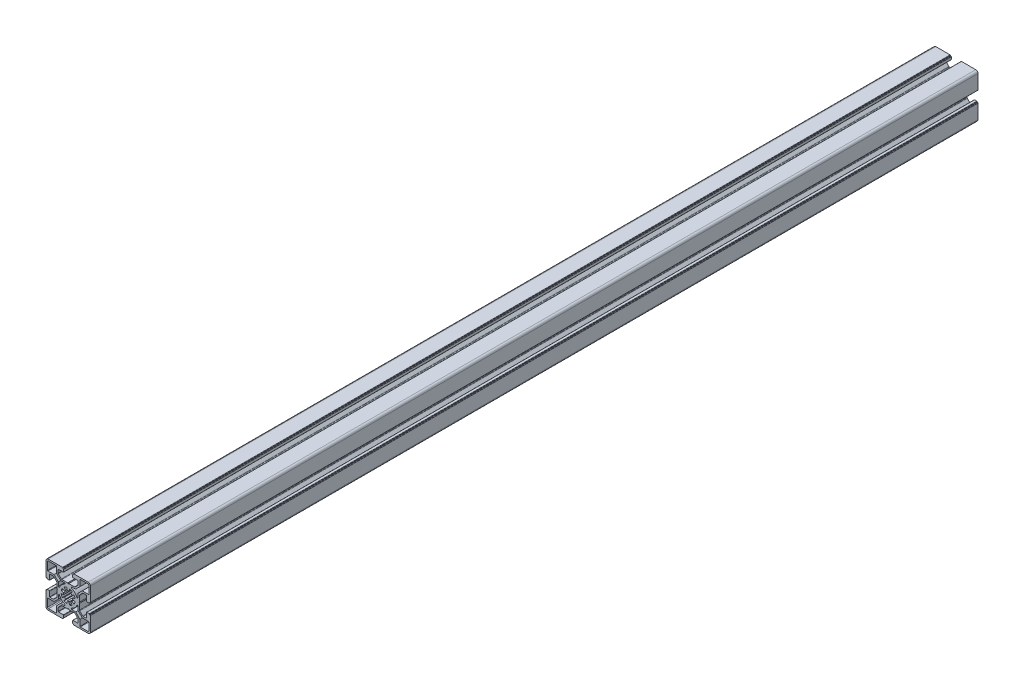
from build123d import *

# Parameters (mm, degrees)
EXTRUDE_2_DEPTH = 1000


with BuildPart() as part:
    # Эскиз2 → Бобышка-Вытянуть2 (new body)
    with BuildSketch(Plane.XY):
        with BuildLine():
            Line((-25, 11.3), (-25, 22.5))
            ThreePointArc((-25, 22.5), (-24.267766953, 24.267766953), (-22.5, 25))
            Line((-22.5, 25), (-11.3, 25))
            Line((-11.3, 25), (-6.4, 25))
            ThreePointArc((-6.4, 25), (-6.187867966, 24.912132034), (-6.1, 24.7))
            Line((-6.1, 24.7), (-6.1, 24))
            Line((-6.1, 24), (-5.4, 24))
            ThreePointArc((-5.4, 24), (-5.187867966, 23.912132034), (-5.1, 23.7))
            Line((-5.1, 23.7), (-5.1, 21.1))
            ThreePointArc((-5.1, 21.1), (-5.187867966, 20.887867966), (-5.4, 20.8))
            Line((-5.4, 20.8), (-11, 20.8))
            ThreePointArc((-11, 20.8), (-11.212132034, 20.712132034), (-11.3, 20.5))
            Line((-11.3, 20.5), (-11.3, 16.914213562))
            ThreePointArc((-11.3, 16.914213562), (-11.223879533, 16.53153013), (-11.007106781, 16.207106781))
            Line((-11.007106781, 16.207106781), (-7.792893219, 12.992893219))
            ThreePointArc((-7.792893219, 12.992893219), (-7.46846987, 12.776120467), (-7.085786438, 12.7))
            Line((-7.085786438, 12.7), (-0.6, 12.7))
            Line((-0.6, 12.7), (0, 12.1))
            Line((0, 12.1), (0.6, 12.7))
            Line((0.6, 12.7), (7.085786438, 12.7))
            ThreePointArc((7.085786438, 12.7), (7.46846987, 12.776120467), (7.792893219, 12.992893219))
            Line((7.792893219, 12.992893219), (11.007106781, 16.207106781))
            ThreePointArc((11.007106781, 16.207106781), (11.223879533, 16.53153013), (11.3, 16.914213562))
            Line((11.3, 16.914213562), (11.3, 20.5))
            ThreePointArc((11.3, 20.5), (11.212132034, 20.712132034), (11, 20.8))
            Line((11, 20.8), (5.4, 20.8))
            ThreePointArc((5.4, 20.8), (5.187867966, 20.887867966), (5.1, 21.1))
            Line((5.1, 21.1), (5.1, 23.7))
            ThreePointArc((5.1, 23.7), (5.187867966, 23.912132034), (5.4, 24))
            Line((5.4, 24), (6.1, 24))
            Line((6.1, 24), (6.1, 24.7))
            ThreePointArc((6.1, 24.7), (6.187867966, 24.912132034), (6.4, 25))
            Line((6.4, 25), (11.3, 25))
            Line((11.3, 25), (22.5, 25))
            ThreePointArc((22.5, 25), (24.267766953, 24.267766953), (25, 22.5))
            Line((25, 22.5), (25, 11.3))
            Line((25, 11.3), (25, 6.4))
            ThreePointArc((25, 6.4), (24.912132034, 6.187867966), (24.7, 6.1))
            Line((24.7, 6.1), (24, 6.1))
            Line((24, 6.1), (24, 5.4))
            ThreePointArc((24, 5.4), (23.912132034, 5.187867966), (23.7, 5.1))
            Line((23.7, 5.1), (21.1, 5.1))
            ThreePointArc((21.1, 5.1), (20.887867966, 5.187867966), (20.8, 5.4))
            Line((20.8, 5.4), (20.8, 11))
            ThreePointArc((20.8, 11), (20.712132034, 11.212132034), (20.5, 11.3))
            Line((20.5, 11.3), (16.914213562, 11.3))
            ThreePointArc((16.914213562, 11.3), (16.53153013, 11.223879533), (16.207106781, 11.007106781))
            Line((16.207106781, 11.007106781), (12.992893219, 7.792893219))
            ThreePointArc((12.992893219, 7.792893219), (12.776120467, 7.46846987), (12.7, 7.085786438))
            Line((12.7, 7.085786438), (12.7, 0.6))
            Line((12.7, 0.6), (12.1, 0))
            Line((12.1, 0), (12.7, -0.6))
            Line((12.7, -0.6), (12.7, -7.085786438))
            ThreePointArc((12.7, -7.085786438), (12.776120467, -7.46846987), (12.992893219, -7.792893219))
            Line((12.992893219, -7.792893219), (16.207106781, -11.007106781))
            ThreePointArc((16.207106781, -11.007106781), (16.53153013, -11.223879533), (16.914213562, -11.3))
            Line((16.914213562, -11.3), (20.5, -11.3))
            ThreePointArc((20.5, -11.3), (20.712132034, -11.212132034), (20.8, -11))
            Line((20.8, -11), (20.8, -5.4))
            ThreePointArc((20.8, -5.4), (20.887867966, -5.187867966), (21.1, -5.1))
            Line((21.1, -5.1), (23.7, -5.1))
            ThreePointArc((23.7, -5.1), (23.912132034, -5.187867966), (24, -5.4))
            Line((24, -5.4), (24, -6.1))
            Line((24, -6.1), (24.7, -6.1))
            ThreePointArc((24.7, -6.1), (24.912132034, -6.187867966), (25, -6.4))
            Line((25, -6.4), (25, -11.3))
            Line((25, -11.3), (25, -22.5))
            ThreePointArc((25, -22.5), (24.267766953, -24.267766953), (22.5, -25))
            Line((22.5, -25), (11.3, -25))
            Line((11.3, -25), (6.4, -25))
            ThreePointArc((6.4, -25), (6.187867966, -24.912132034), (6.1, -24.7))
            Line((6.1, -24.7), (6.1, -24))
            Line((6.1, -24), (5.4, -24))
            ThreePointArc((5.4, -24), (5.187867966, -23.912132034), (5.1, -23.7))
            Line((5.1, -23.7), (5.1, -21.1))
            ThreePointArc((5.1, -21.1), (5.187867966, -20.887867966), (5.4, -20.8))
            Line((5.4, -20.8), (11, -20.8))
            ThreePointArc((11, -20.8), (11.212132034, -20.712132034), (11.3, -20.5))
            Line((11.3, -20.5), (11.3, -16.914213562))
            ThreePointArc((11.3, -16.914213562), (11.223879533, -16.53153013), (11.007106781, -16.207106781))
            Line((11.007106781, -16.207106781), (7.792893219, -12.992893219))
            ThreePointArc((7.792893219, -12.992893219), (7.46846987, -12.776120467), (7.085786438, -12.7))
            Line((7.085786438, -12.7), (0.6, -12.7))
            Line((0.6, -12.7), (0, -12.1))
            Line((0, -12.1), (-0.6, -12.7))
            Line((-0.6, -12.7), (-7.085786438, -12.7))
            ThreePointArc((-7.085786438, -12.7), (-7.46846987, -12.776120467), (-7.792893219, -12.992893219))
            Line((-7.792893219, -12.992893219), (-11.007106781, -16.207106781))
            ThreePointArc((-11.007106781, -16.207106781), (-11.223879533, -16.53153013), (-11.3, -16.914213562))
            Line((-11.3, -16.914213562), (-11.3, -20.5))
            ThreePointArc((-11.3, -20.5), (-11.212132034, -20.712132034), (-11, -20.8))
            Line((-11, -20.8), (-5.4, -20.8))
            ThreePointArc((-5.4, -20.8), (-5.187867966, -20.887867966), (-5.1, -21.1))
            Line((-5.1, -21.1), (-5.1, -23.7))
            ThreePointArc((-5.1, -23.7), (-5.187867966, -23.912132034), (-5.4, -24))
            Line((-5.4, -24), (-6.1, -24))
            Line((-6.1, -24), (-6.1, -24.7))
            ThreePointArc((-6.1, -24.7), (-6.187867966, -24.912132034), (-6.4, -25))
            Line((-6.4, -25), (-11.3, -25))
            Line((-11.3, -25), (-22.5, -25))
            ThreePointArc((-22.5, -25), (-24.267766953, -24.267766953), (-25, -22.5))
            Line((-25, -22.5), (-25, -11.3))
            Line((-25, -11.3), (-25, -6.4))
            ThreePointArc((-25, -6.4), (-24.912132034, -6.187867966), (-24.7, -6.1))
            Line((-24.7, -6.1), (-24, -6.1))
            Line((-24, -6.1), (-24, -5.4))
            ThreePointArc((-24, -5.4), (-23.912132034, -5.187867966), (-23.7, -5.1))
            Line((-23.7, -5.1), (-21.1, -5.1))
            ThreePointArc((-21.1, -5.1), (-20.887867966, -5.187867966), (-20.8, -5.4))
            Line((-20.8, -5.4), (-20.8, -11))
            ThreePointArc((-20.8, -11), (-20.712132034, -11.212132034), (-20.5, -11.3))
            Line((-20.5, -11.3), (-16.914213562, -11.3))
            ThreePointArc((-16.914213562, -11.3), (-16.53153013, -11.223879533), (-16.207106781, -11.007106781))
            Line((-16.207106781, -11.007106781), (-12.992893219, -7.792893219))
            ThreePointArc((-12.992893219, -7.792893219), (-12.776120467, -7.46846987), (-12.7, -7.085786438))
            Line((-12.7, -7.085786438), (-12.7, -0.6))
            Line((-12.7, -0.6), (-12.1, 0))
            Line((-12.1, 0), (-12.7, 0.6))
            Line((-12.7, 0.6), (-12.7, 7.085786438))
            ThreePointArc((-12.7, 7.085786438), (-12.776120467, 7.46846987), (-12.992893219, 7.792893219))
            Line((-12.992893219, 7.792893219), (-16.207106781, 11.007106781))
            ThreePointArc((-16.207106781, 11.007106781), (-16.53153013, 11.223879533), (-16.914213562, 11.3))
            Line((-16.914213562, 11.3), (-20.5, 11.3))
            ThreePointArc((-20.5, 11.3), (-20.712132034, 11.212132034), (-20.8, 11))
            Line((-20.8, 11), (-20.8, 5.4))
            ThreePointArc((-20.8, 5.4), (-20.887867966, 5.187867966), (-21.1, 5.1))
            Line((-21.1, 5.1), (-23.7, 5.1))
            ThreePointArc((-23.7, 5.1), (-23.912132034, 5.187867966), (-24, 5.4))
            Line((-24, 5.4), (-24, 6.1))
            Line((-24, 6.1), (-24.7, 6.1))
            ThreePointArc((-24.7, 6.1), (-24.912132034, 6.187867966), (-25, 6.4))
            Line((-25, 6.4), (-25, 11.3))
        make_face()
        with BuildLine():
            Line((-11.1, 8.412994231), (-11.1, 4.156921938))
            ThreePointArc((-11.1, 4.156921938), (-10.532287566, 3.469535584), (-9.75, 3.897114317))
            ThreePointArc((-9.75, 3.897114317), (-7.424621202, 7.424621202), (-3.897114317, 9.75))
            ThreePointArc((-3.897114317, 9.75), (-3.469535584, 10.532287566), (-4.156921938, 11.1))
            Line((-4.156921938, 11.1), (-8.412994231, 11.1))
            Line((-8.412994231, 11.1), (-13.2, 15.887005769))
            Line((-13.2, 15.887005769), (-13.2, 22.7))
            ThreePointArc((-13.2, 22.7), (-13.346446609, 23.053553391), (-13.7, 23.2))
            Line((-13.7, 23.2), (-22.2, 23.2))
            ThreePointArc((-22.2, 23.2), (-22.907106781, 22.907106781), (-23.2, 22.2))
            Line((-23.2, 22.2), (-23.2, 13.7))
            ThreePointArc((-23.2, 13.7), (-23.053553391, 13.346446609), (-22.7, 13.2))
            Line((-22.7, 13.2), (-15.887005769, 13.2))
            Line((-15.887005769, 13.2), (-11.1, 8.412994231))
        make_face(mode=Mode.SUBTRACT)
        with BuildLine():
            Line((22.7, 13.2), (15.887005769, 13.2))
            Line((15.887005769, 13.2), (11.1, 8.412994231))
            Line((11.1, 8.412994231), (11.1, 4.156921938))
            ThreePointArc((11.1, 4.156921938), (10.532287566, 3.469535584), (9.75, 3.897114317))
            ThreePointArc((9.75, 3.897114317), (7.424621202, 7.424621202), (3.897114317, 9.75))
            ThreePointArc((3.897114317, 9.75), (3.469535584, 10.532287566), (4.156921938, 11.1))
            Line((4.156921938, 11.1), (8.412994231, 11.1))
            Line((8.412994231, 11.1), (13.2, 15.887005769))
            Line((13.2, 15.887005769), (13.2, 22.7))
            ThreePointArc((13.2, 22.7), (13.346446609, 23.053553391), (13.7, 23.2))
            Line((13.7, 23.2), (22.2, 23.2))
            ThreePointArc((22.2, 23.2), (22.907106781, 22.907106781), (23.2, 22.2))
            Line((23.2, 22.2), (23.2, 13.7))
            ThreePointArc((23.2, 13.7), (23.053553391, 13.346446609), (22.7, 13.2))
        make_face(mode=Mode.SUBTRACT)
        with BuildLine():
            Line((8.412994231, -11.1), (13.2, -15.887005769))
            Line((13.2, -15.887005769), (13.2, -22.7))
            ThreePointArc((13.2, -22.7), (13.346446609, -23.053553391), (13.7, -23.2))
            Line((13.7, -23.2), (22.2, -23.2))
            ThreePointArc((22.2, -23.2), (22.907106781, -22.907106781), (23.2, -22.2))
            Line((23.2, -22.2), (23.2, -13.7))
            ThreePointArc((23.2, -13.7), (23.053553391, -13.346446609), (22.7, -13.2))
            Line((22.7, -13.2), (15.887005769, -13.2))
            Line((15.887005769, -13.2), (11.1, -8.412994231))
            Line((11.1, -8.412994231), (11.1, -4.156921938))
            ThreePointArc((11.1, -4.156921938), (10.532287566, -3.469535584), (9.75, -3.897114317))
            ThreePointArc((9.75, -3.897114317), (7.424621202, -7.424621202), (3.897114317, -9.75))
            ThreePointArc((3.897114317, -9.75), (3.469535584, -10.532287566), (4.156921938, -11.1))
            Line((4.156921938, -11.1), (8.412994231, -11.1))
        make_face(mode=Mode.SUBTRACT)
        with BuildLine():
            Line((-11.1, -8.412994231), (-15.887005769, -13.2))
            Line((-15.887005769, -13.2), (-22.7, -13.2))
            ThreePointArc((-22.7, -13.2), (-23.053553391, -13.346446609), (-23.2, -13.7))
            Line((-23.2, -13.7), (-23.2, -22.2))
            ThreePointArc((-23.2, -22.2), (-22.907106781, -22.907106781), (-22.2, -23.2))
            Line((-22.2, -23.2), (-13.7, -23.2))
            ThreePointArc((-13.7, -23.2), (-13.346446609, -23.053553391), (-13.2, -22.7))
            Line((-13.2, -22.7), (-13.2, -15.887005769))
            Line((-13.2, -15.887005769), (-8.412994231, -11.1))
            Line((-8.412994231, -11.1), (-4.156921938, -11.1))
            ThreePointArc((-4.156921938, -11.1), (-3.469535584, -10.532287566), (-3.897114317, -9.75))
            ThreePointArc((-3.897114317, -9.75), (-7.424621202, -7.424621202), (-9.75, -3.897114317))
            ThreePointArc((-9.75, -3.897114317), (-10.532287566, -3.469535584), (-11.1, -4.156921938))
            Line((-11.1, -4.156921938), (-11.1, -8.412994231))
        make_face(mode=Mode.SUBTRACT)
        with BuildLine():
            Line((1.457884204, 7.866039261), (0.92940118, 5.014600029))
            ThreePointArc((0.92940118, 5.014600029), (0, 5.1), (-0.92940118, 5.014600029))
            Line((-0.92940118, 5.014600029), (-1.457884204, 7.866039261))
            ThreePointArc((-1.457884204, 7.866039261), (-3.061467459, 7.39103626), (-4.531249895, 6.593009509))
            Line((-4.531249895, 6.593009509), (-2.888671808, 4.203043562))
            ThreePointArc((-2.888671808, 4.203043562), (-3.606244584, 3.606244584), (-4.203043562, 2.888671808))
            Line((-4.203043562, 2.888671808), (-6.593009509, 4.531249895))
            ThreePointArc((-6.593009509, 4.531249895), (-7.39103626, 3.061467459), (-7.866039261, 1.457884204))
            Line((-7.866039261, 1.457884204), (-5.014600029, 0.92940118))
            ThreePointArc((-5.014600029, 0.92940118), (-5.1, 0), (-5.014600029, -0.92940118))
            Line((-5.014600029, -0.92940118), (-7.866039261, -1.457884204))
            ThreePointArc((-7.866039261, -1.457884204), (-7.39103626, -3.061467459), (-6.593009509, -4.531249895))
            Line((-6.593009509, -4.531249895), (-4.203043562, -2.888671808))
            ThreePointArc((-4.203043562, -2.888671808), (-3.606244584, -3.606244584), (-2.888671808, -4.203043562))
            Line((-2.888671808, -4.203043562), (-4.531249895, -6.593009509))
            ThreePointArc((-4.531249895, -6.593009509), (-3.061467459, -7.39103626), (-1.457884204, -7.866039261))
            Line((-1.457884204, -7.866039261), (-0.92940118, -5.014600029))
            ThreePointArc((-0.92940118, -5.014600029), (0, -5.1), (0.92940118, -5.014600029))
            Line((0.92940118, -5.014600029), (1.457884204, -7.866039261))
            ThreePointArc((1.457884204, -7.866039261), (3.061467459, -7.39103626), (4.531249895, -6.593009509))
            Line((4.531249895, -6.593009509), (2.888671808, -4.203043562))
            ThreePointArc((2.888671808, -4.203043562), (3.606244584, -3.606244584), (4.203043562, -2.888671808))
            Line((4.203043562, -2.888671808), (6.593009509, -4.531249895))
            ThreePointArc((6.593009509, -4.531249895), (7.39103626, -3.061467459), (7.866039261, -1.457884204))
            Line((7.866039261, -1.457884204), (5.014600029, -0.92940118))
            ThreePointArc((5.014600029, -0.92940118), (5.1, 0), (5.014600029, 0.92940118))
            Line((5.014600029, 0.92940118), (7.866039261, 1.457884204))
            ThreePointArc((7.866039261, 1.457884204), (7.39103626, 3.061467459), (6.593009509, 4.531249895))
            Line((6.593009509, 4.531249895), (4.203043562, 2.888671808))
            ThreePointArc((4.203043562, 2.888671808), (3.606244584, 3.606244584), (2.888671808, 4.203043562))
            Line((2.888671808, 4.203043562), (4.531249895, 6.593009509))
            ThreePointArc((4.531249895, 6.593009509), (3.061467459, 7.39103626), (1.457884204, 7.866039261))
        make_face(mode=Mode.SUBTRACT)
    extrude(amount=EXTRUDE_2_DEPTH)


solid = part.part
